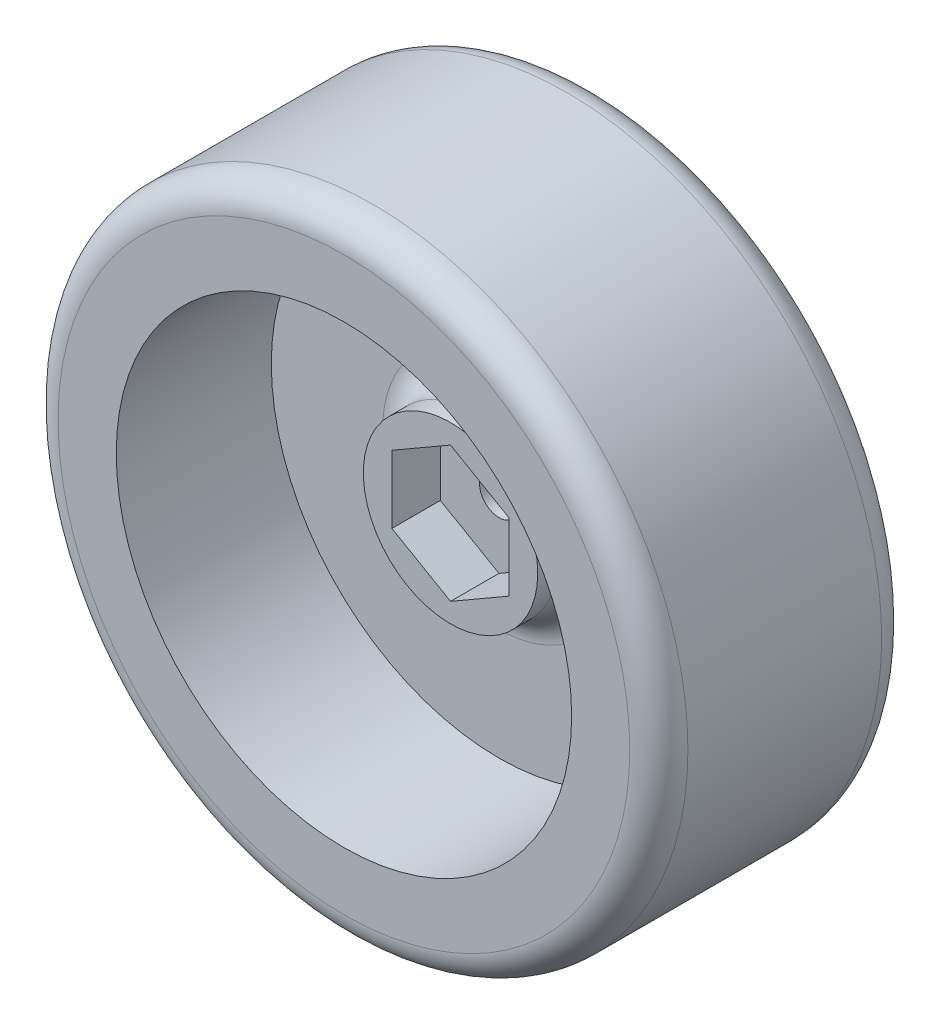
from build123d import *

# Parameters (mm, degrees)
SKETCH1_R           = 32.5
SKETCH1_R_2         = 2
BOSS_EXTRUDE1_DEPTH = 26
FILLET1_R           = 3
SKETCH2_R           = 23.5
CUT_EXTRUDE1_DEPTH  = 16
SKETCH3_R           = 9
BOSS_EXTRUDE2_DEPTH = 5
SKETCH4_R           = 7.5
CUT_EXTRUDE2_DEPTH  = 2
SKETCH5_R           = 5
CUT_EXTRUDE3_DEPTH  = 4
FILLET2_R           = 3


with BuildPart() as part:
    # Sketch1 → Boss-Extrude1 (new body)
    with BuildSketch(Plane.XY):
        Circle(SKETCH1_R)
        Circle(SKETCH1_R_2, mode=Mode.SUBTRACT)
    extrude(amount=BOSS_EXTRUDE1_DEPTH)

    # Fillet1
    fillet1_edges = [part.edges().sort_by_distance(p)[0] for p in [
        (-32.5, 0, 0),
        (-32.5, 0, 26),
    ]]
    fillet(fillet1_edges, radius=FILLET1_R)

    # Sketch2 → Cut-Extrude1 (cut)
    with BuildSketch(Plane.XY.offset(26)):
        Circle(SKETCH2_R)
    extrude(amount=-CUT_EXTRUDE1_DEPTH, mode=Mode.SUBTRACT)

    # Sketch3 → Boss-Extrude2 (add)
    with BuildSketch(Plane.XY.offset(10)):
        Circle(SKETCH3_R)
        Polygon((-6.05, -3.492969129), (-6.05, 3.492969129), (0, 6.985938257), (6.05, 3.492969129), (6.05, -3.492969129), (0, -6.985938257), align=None, mode=Mode.SUBTRACT)
    extrude(amount=BOSS_EXTRUDE2_DEPTH)

    # Sketch4 → Cut-Extrude2 (cut)
    with BuildSketch(Plane(origin=(0, 0, 0), x_dir=(-1, 0, 0), z_dir=(0, 0, -1))):
        Circle(SKETCH4_R)
    extrude(amount=-CUT_EXTRUDE2_DEPTH, mode=Mode.SUBTRACT)

    # Sketch5 → Cut-Extrude3 (cut)
    with BuildSketch(Plane(origin=(0, 0, 2), x_dir=(-1, 0, 0), z_dir=(0, 0, -1))):
        Circle(SKETCH5_R)
    extrude(amount=-CUT_EXTRUDE3_DEPTH, mode=Mode.SUBTRACT)

    # Fillet2
    fillet2_edges = [part.edges().sort_by_distance(p)[0] for p in [
        (-9, 0, 10),
    ]]
    fillet(fillet2_edges, radius=FILLET2_R)


solid = part.part
